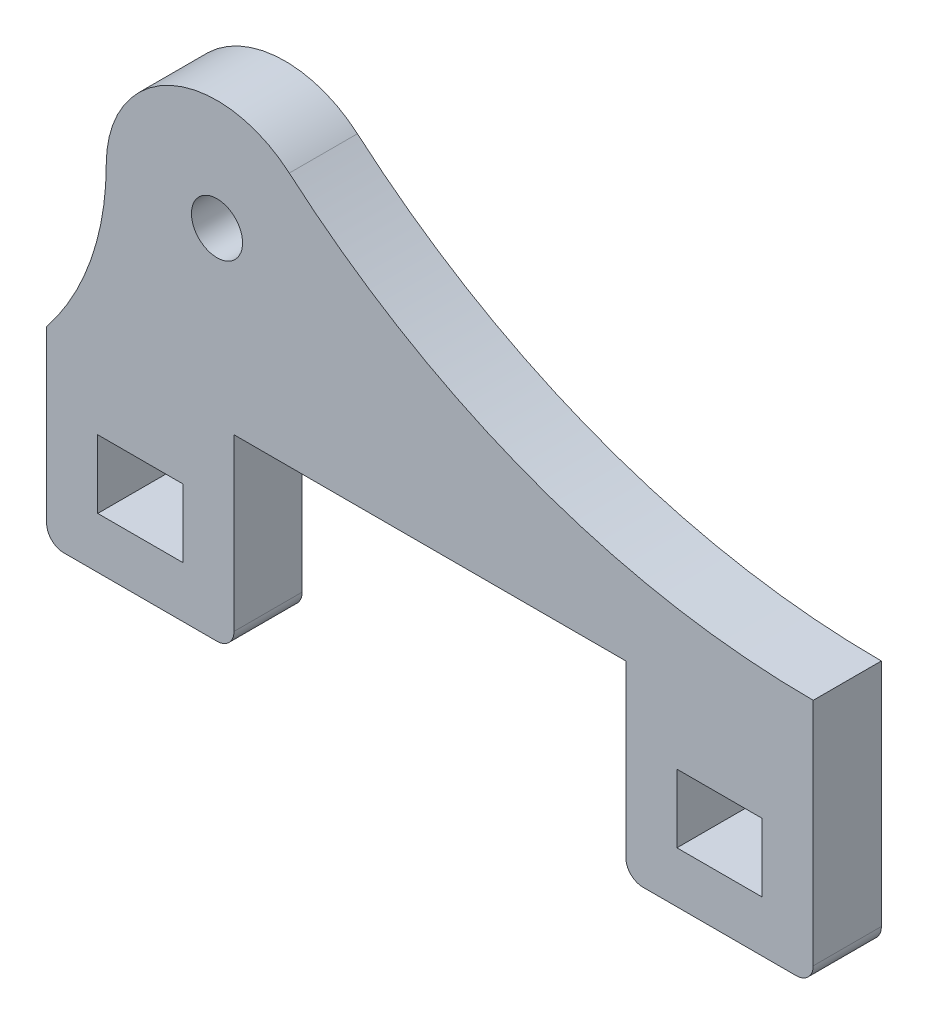
from build123d import *

# Parameters (mm, degrees)
SKETCH1_W           = 5
SKETCH1_H           = 4
SKETCH1_R           = 1.5
BOSS_EXTRUDE1_DEPTH = 4
FILLET3_R           = 1


with BuildPart() as part:
    # Sketch1 → Boss-Extrude1 (new body)
    with BuildSketch(Plane.XY):
        with BuildLine():
            ThreePointArc((3.5, 10), (2.599728643, 4.702594975), (0, 0))
            Line((0, 0), (0, -11))
            Line((0, -11), (11, -11))
            Line((11, -11), (11, 0))
            Line((11, 0), (34, 0))
            Line((34, 0), (34, -11))
            Line((34, -11), (45, -11))
            Line((45, -11), (45, 3.5))
            ThreePointArc((45, 3.5), (28.59505774, 6.448232376), (14.243185079, 14.923959828))
            ThreePointArc((14.243185079, 14.923959828), (7.291744382, 15.908921349), (3.5, 10))
        make_face()
        with Locations((5.5, -6)):
            Rectangle(SKETCH1_W, SKETCH1_H, mode=Mode.SUBTRACT)
        with Locations((39.5, -6)):
            Rectangle(SKETCH1_W, SKETCH1_H, mode=Mode.SUBTRACT)
        with Locations((10, 10)):
            Circle(SKETCH1_R, mode=Mode.SUBTRACT)
    extrude(amount=BOSS_EXTRUDE1_DEPTH)

    # Fillet3
    fillet3_edges = [part.edges().sort_by_distance(p)[0] for p in [
        (45, -11, 2),
        (34, -11, 2),
        (11, -11, 2),
        (0, -11, 2),
    ]]
    fillet(fillet3_edges, radius=FILLET3_R)


solid = part.part
